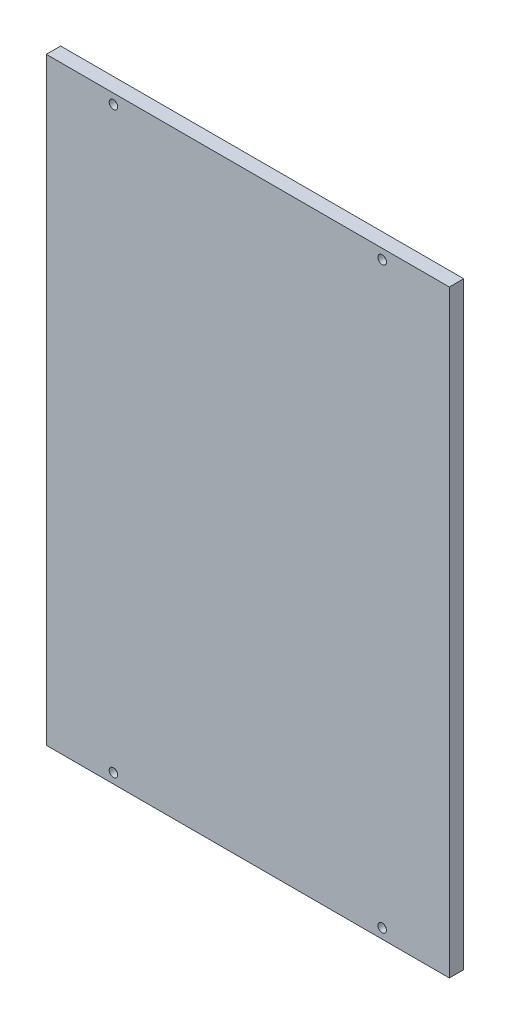
from build123d import *

# Parameters (mm, degrees)
ESBO_O1_W                = 300
ESBO_O1_H                = 445.4
RESSALTO_EXTRUS_O1_DEPTH = 10.7
FURO1_D                  = 6.35
FURO1_CBORE_D            = 9.52
FURO1_CBORE_DEPTH        = 6.35


with BuildPart() as part:
    # Esboço1 → Ressalto-extrusão1 (new body)
    with BuildSketch(Plane.XY):
        Rectangle(ESBO_O1_W, ESBO_O1_H)
    extrude(amount=RESSALTO_EXTRUS_O1_DEPTH)

    # Furo1 (through all)
    with Locations(Plane(origin=(0, 0, 0), x_dir=(-1, 0, 0), z_dir=(0, 0, -1))):
        with Locations((-100, 215.35), (-100, -215.35), (100, -215.35), (100, 215.35)):
            CounterBoreHole(FURO1_D / 2, FURO1_CBORE_D / 2, FURO1_CBORE_DEPTH)


solid = part.part
